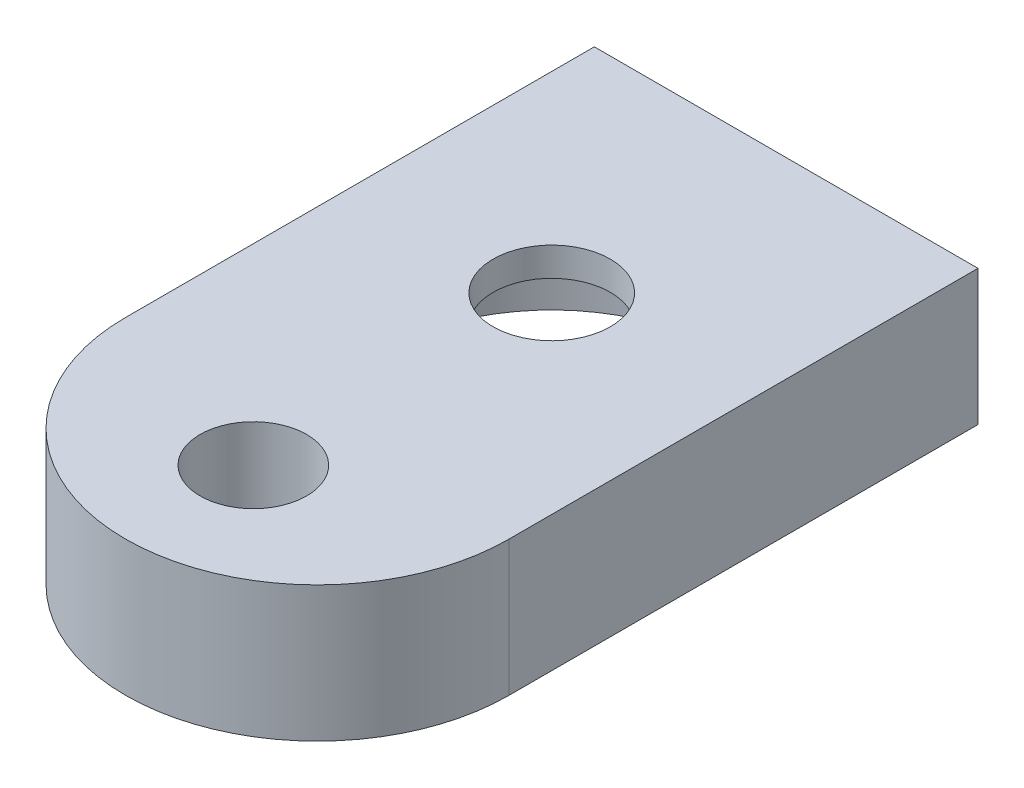
from build123d import *

# Parameters (mm, degrees)
BOSS_EXTRUDE1_DEPTH = 6.35
SKETCH2_R           = 8
CUT_EXTRUDE1_DEPTH  = 5
SKETCH3_R           = 2.75
CUT_EXTRUDE2_DEPTH  = 2.35
SKETCH4_R           = 2.5
CUT_EXTRUDE3_DEPTH  = 7.35


with BuildPart() as part:
    # Sketch1 → Boss-Extrude1 (new body)
    with BuildSketch(Plane(origin=(0, 0, 0), x_dir=(1, 0, 0), z_dir=(0, 1, 0))):
        with BuildLine():
            Line((9, 11), (-9, 11))
            Line((-9, 11), (-9, -11))
            ThreePointArc((-9, -11), (0, -20), (9, -11))
            Line((9, -11), (9, 11))
        make_face()
    extrude(amount=BOSS_EXTRUDE1_DEPTH)

    # Sketch2 → Cut-Extrude1 (cut)
    with BuildSketch(Plane.XZ):
        Circle(SKETCH2_R)
    extrude(amount=-CUT_EXTRUDE1_DEPTH, mode=Mode.SUBTRACT)

    # Sketch3 → Cut-Extrude2 (cut, through all)
    with BuildSketch(Plane.XZ.offset(-5)):
        Circle(SKETCH3_R)
    extrude(amount=-CUT_EXTRUDE2_DEPTH, mode=Mode.SUBTRACT)

    # Sketch4 → Cut-Extrude3 (cut, through all)
    with BuildSketch(Plane.XZ):
        with Locations((0, 14)):
            Circle(SKETCH4_R)
        with Locations((0, -13.5)):
            Circle(SKETCH4_R)
    extrude(amount=-CUT_EXTRUDE3_DEPTH, mode=Mode.SUBTRACT)


solid = part.part
